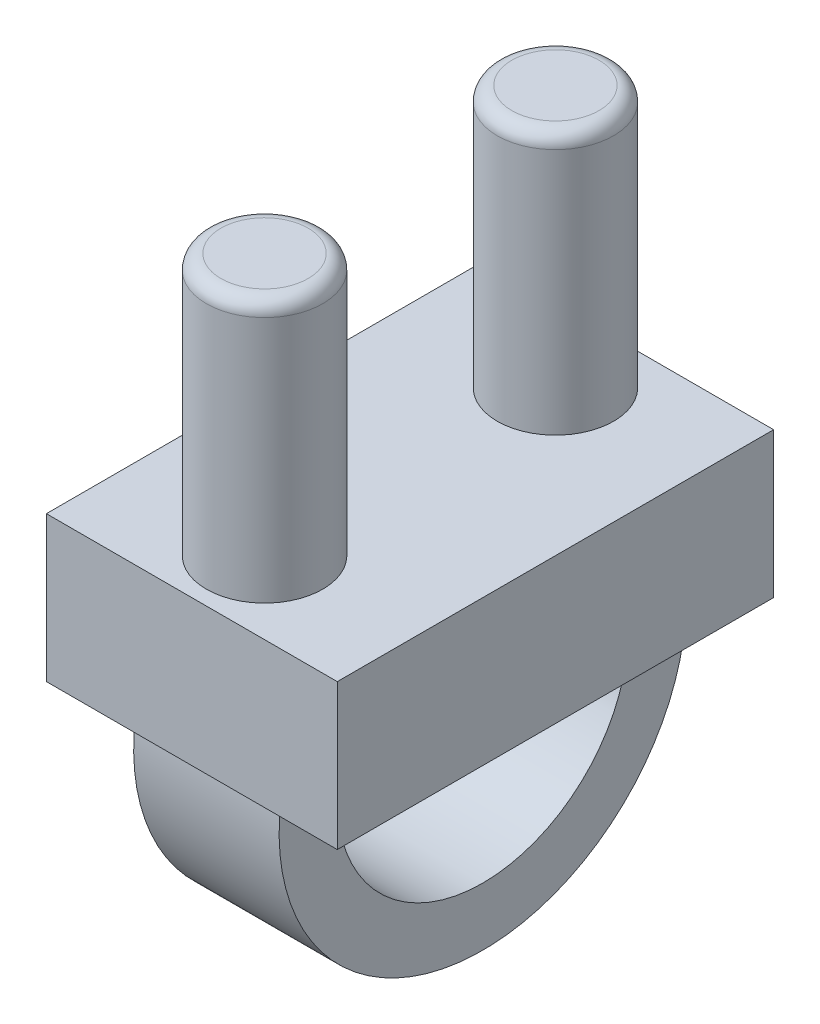
from build123d import *

# Parameters (mm, degrees)
SKETCH1_W                     = 2
SKETCH1_H                     = 3
NP2_IMPLANTER_LOCK_BASE_DEPTH = 1
SKETCH2_R                     = 0.4
LOCK_ARMS_DEPTH               = 1.8
RETREIVAL_HOOKS_DEPTH         = 0.5
FILLET1_R                     = 0.1


with BuildPart() as part:
    # Sketch1 → NP2 Implanter Lock Base (new body)
    with BuildSketch(Plane(origin=(0, 0, 0), x_dir=(1, 0, 0), z_dir=(0, 1, 0))):
        Rectangle(SKETCH1_W, SKETCH1_H)
    extrude(amount=NP2_IMPLANTER_LOCK_BASE_DEPTH)

    # Sketch2 → Lock arms (add)
    with BuildSketch(Plane(origin=(0, 1, 0), x_dir=(1, 0, 0), z_dir=(0, 1, 0))):
        with Locations((0, 1)):
            Circle(SKETCH2_R)
        with Locations((0, -1)):
            Circle(SKETCH2_R)
    extrude(amount=LOCK_ARMS_DEPTH)

    # Sketch3 → Retreival Hooks (add, symmetric)
    with BuildSketch(Plane(origin=(0, 0, 0), x_dir=(0, 0, -1), z_dir=(1, 0, 0))):
        with BuildLine():
            Line((-1.385640646, 0), (-0.979795897, 0))
            ThreePointArc((-0.979795897, 0), (0, -1.2), (0.979795897, 0))
            Line((0.979795897, 0), (1.385640646, 0))
            ThreePointArc((1.385640646, 0), (0, -1.6), (-1.385640646, 0))
        make_face()
    extrude(amount=RETREIVAL_HOOKS_DEPTH, both=True)

    # Fillet1
    fillet1_edges = [part.edges().sort_by_distance(p)[0] for p in [
        (-0.4, 2.8, -1),
        (-0.4, 2.8, 1),
    ]]
    fillet(fillet1_edges, radius=FILLET1_R)


solid = part.part
